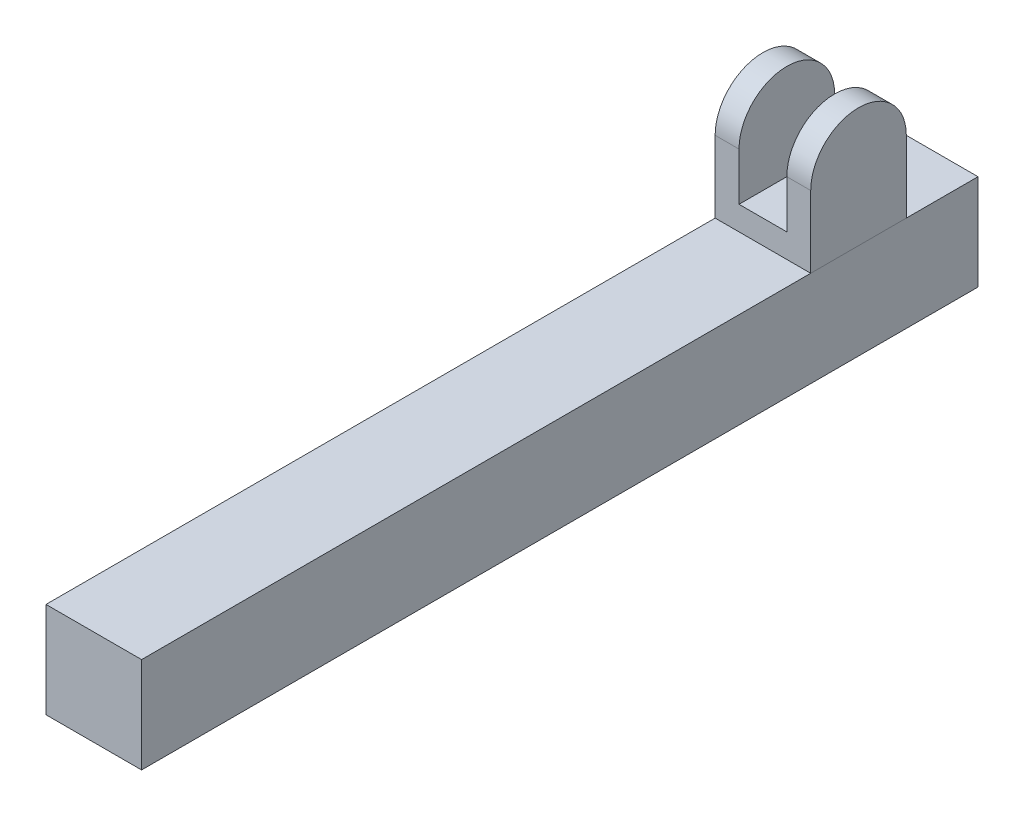
from build123d import *

# Parameters (mm, degrees)
SKETCH_1_W           = 8
SKETCH_1_H           = 8
EXTRUDE_1_DEPTH      = 70
SKETCH_2_R           = 3
CUT_EXTRUDE_1_DEPTH  = 65
EXTRUDE_2_DEPTH      = 8
SKETCH_8_W           = 4
SKETCH_8_H           = 8
CUT_EXTRUDE_10_DEPTH = 12


with BuildPart() as part:
    # 草图1 → 凸台-拉伸1 (new body)
    with BuildSketch(Plane.XY):
        Rectangle(SKETCH_1_W, SKETCH_1_H)
    extrude(amount=EXTRUDE_1_DEPTH)

    # 草图2 → 切除-拉伸1 (cut)
    with BuildSketch(Plane(origin=(0, 0, 0), x_dir=(-1, 0, 0), z_dir=(0, 0, -1))):
        Circle(SKETCH_2_R)
    extrude(amount=-CUT_EXTRUDE_1_DEPTH, mode=Mode.SUBTRACT)


with BuildPart() as body_2:
    # 草图3 → 凸台-拉伸2 (new body)
    with BuildSketch(Plane.ZY.offset(4)):
        with BuildLine():
            Line((6, 4), (14, 4))
            Line((14, 4), (14, 10))
            ThreePointArc((14, 10), (10, 14), (6, 10))
            Line((6, 10), (6, 4))
        make_face()
    extrude(amount=-EXTRUDE_2_DEPTH)

    # 草图8 → 切除-拉伸10 (cut)
    with BuildSketch(Plane(origin=(0, 0, 6), x_dir=(-1, 0, 0), z_dir=(0, 0, -1))):
        with Locations((0, 10)):
            Rectangle(SKETCH_8_W, SKETCH_8_H)
    extrude(amount=-CUT_EXTRUDE_10_DEPTH, mode=Mode.SUBTRACT)


solid = Compound([part.part, body_2.part])
